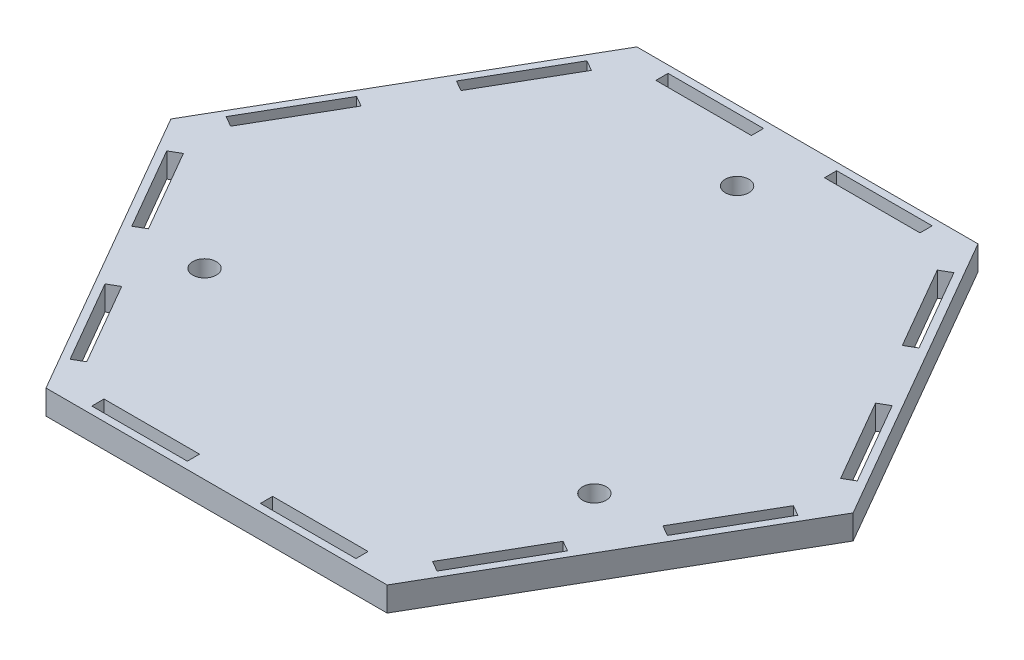
from build123d import *

# Parameters (mm, degrees)
BOSS_EXTRUDE1_DEPTH = 6.35
SKETCH2_R           = 3.0734
SKETCH2_W           = 24.892
SKETCH2_H           = 3.175
CUT_EXTRUDE1_DEPTH  = 7.35


with BuildPart() as part:
    # Sketch1 → Boss-Extrude1 (new body)
    with BuildSketch(Plane(origin=(0, 0, 0), x_dir=(1, 0, 0), z_dir=(0, 1, 0))):
        Polygon((-88.9, 0), (-44.45, -76.989658396), (44.45, -76.989658396), (88.9, 0), (44.45, 76.989658396), (-44.45, 76.989658396), align=None)
    extrude(amount=BOSS_EXTRUDE1_DEPTH)

    # Sketch2 → Cut-Extrude1 (cut, through all)
    with BuildSketch(Plane(origin=(0, 6.35, 0), x_dir=(1, 0, 0), z_dir=(0, 1, 0))):
        with Locations((-50.8, -29.329393675)):
            Circle(SKETCH2_R)
        with Locations((0, 58.65878735)):
            Circle(SKETCH2_R)
        with Locations((50.8, -29.329393675)):
            Circle(SKETCH2_R)
        Polygon((-79.484090949, -6.148832876), (-82.233721606, -7.736332876), (-69.787721606, -29.293437227), (-67.038090949, -27.705937227), align=None)
        Polygon((-45.067090949, -65.76082552), (-47.816721606, -67.34832552), (-60.262721606, -45.791221169), (-57.513090949, -44.203721169), align=None)
        Polygon((-45.067090949, 65.76082552), (-47.816721606, 67.34832552), (-60.262721606, 45.791221169), (-57.513090949, 44.203721169), align=None)
        Polygon((-69.787721606, 29.293437227), (-67.038090949, 27.705937227), (-79.484090949, 6.148832876), (-82.233721606, 7.736332876), align=None)
        with Locations((21.971, 73.497158396)):
            Rectangle(SKETCH2_W, SKETCH2_H)
        with Locations((-21.971, 73.497158396)):
            Rectangle(SKETCH2_W, SKETCH2_H)
        Polygon((79.484090949, 6.148832876), (82.233721606, 7.736332876), (69.787721606, 29.293437227), (67.038090949, 27.705937227), align=None)
        Polygon((60.262721606, 45.791221169), (57.513090949, 44.203721169), (45.067090949, 65.76082552), (47.816721606, 67.34832552), align=None)
        Polygon((45.067090949, -65.76082552), (47.816721606, -67.34832552), (60.262721606, -45.791221169), (57.513090949, -44.203721169), align=None)
        Polygon((69.787721606, -29.293437227), (67.038090949, -27.705937227), (79.484090949, -6.148832876), (82.233721606, -7.736332876), align=None)
        with Locations((-21.971, -73.497158396)):
            Rectangle(SKETCH2_W, SKETCH2_H)
        with Locations((21.971, -73.497158396)):
            Rectangle(SKETCH2_W, SKETCH2_H)
    extrude(amount=-CUT_EXTRUDE1_DEPTH, mode=Mode.SUBTRACT)


solid = part.part
